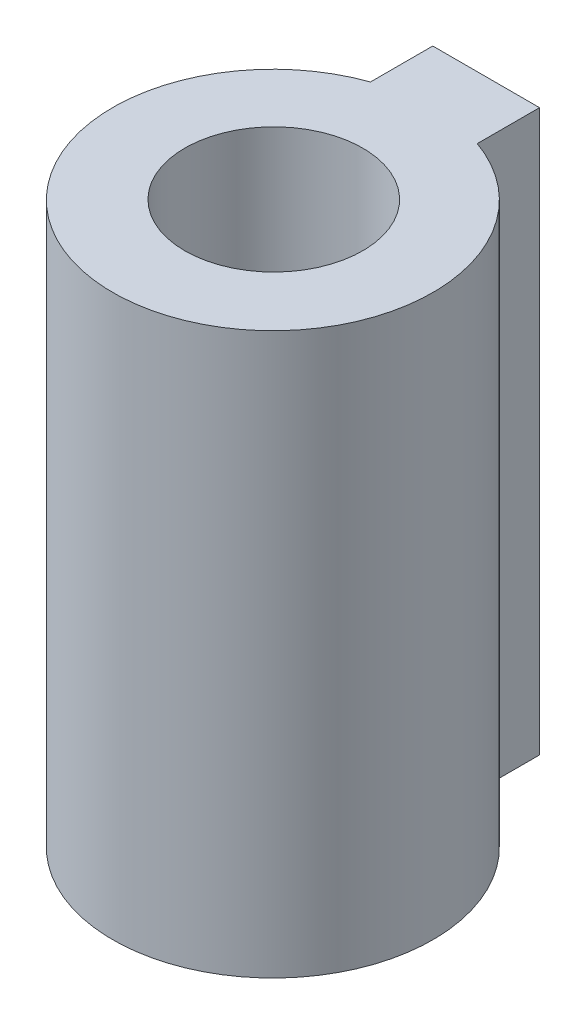
from build123d import *

# Parameters (mm, degrees)
BOSS_EXTRUDE1_DEPTH = 31.5
SKETCH5_R           = 5
CUT_EXTRUDE1_DEPTH  = 25


with BuildPart() as part:
    # Sketch1 → Boss-Extrude1 (new body)
    with BuildSketch(Plane(origin=(0, 0, 0), x_dir=(1, 0, 0), z_dir=(0, 1, 0))):
        with BuildLine():
            ThreePointArc((-1.048467756, 7.218012428), (-2.699998527, 12.414164851), (-7.048467756, 15.703293803))
            ThreePointArc((-7.048467756, 15.703293803), (-10.048467756, 16.218012428), (-13.048467756, 15.703293803))
            ThreePointArc((-13.048467756, 15.703293803), (-15.244620178, -0.1304568), (-1.048467756, 7.218012428))
        make_face()
        with BuildLine():
            ThreePointArc((-13.048467756, 15.703293803), (-10.048467756, 16.218012428), (-7.048467756, 15.703293803))
            Line((-7.048467756, 15.703293803), (-7.048467756, 19.203293803))
            Line((-7.048467756, 19.203293803), (-13.048467756, 19.203293803))
            Line((-13.048467756, 19.203293803), (-13.048467756, 15.703293803))
        make_face()
    extrude(amount=BOSS_EXTRUDE1_DEPTH)

    # Sketch5 → Cut-Extrude1 (cut)
    with BuildSketch(Plane(origin=(0, 31.5, 0), x_dir=(1, 0, 0), z_dir=(0, 1, 0))):
        with Locations((-10.048467756, 7.270239538)):
            Circle(SKETCH5_R)
    extrude(amount=-CUT_EXTRUDE1_DEPTH, mode=Mode.SUBTRACT)


solid = part.part
